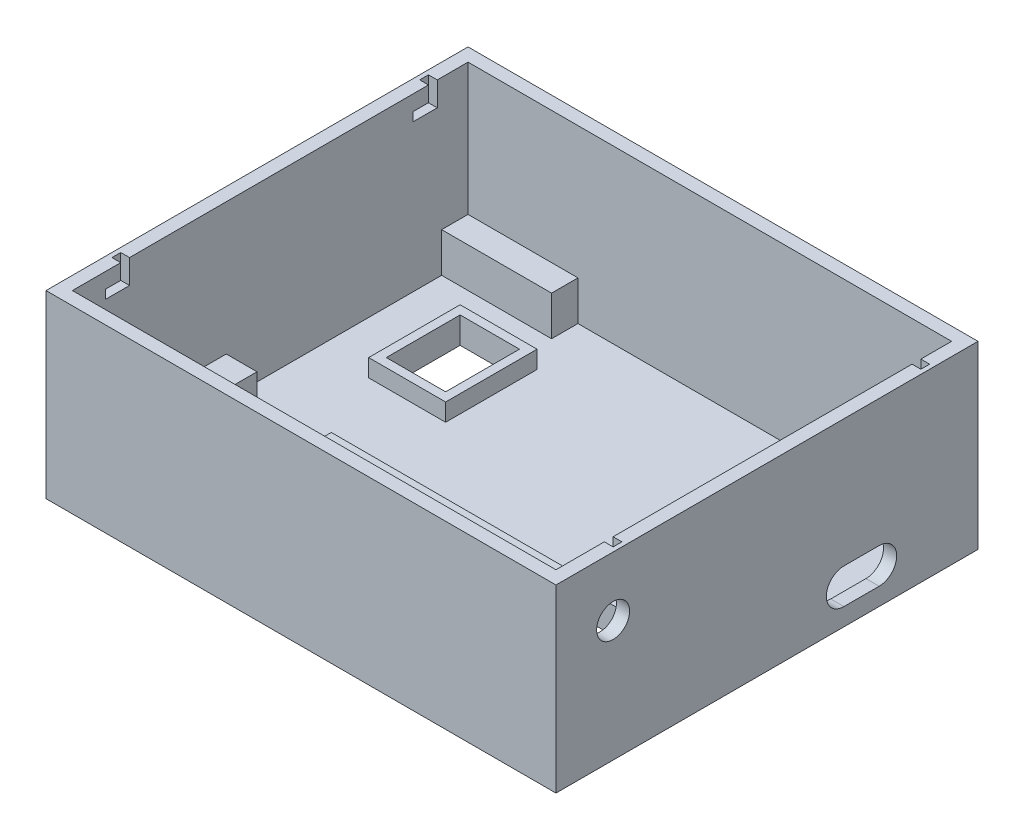
from build123d import *

# Parameters (mm, degrees)
SKETCH1_W           = 116
SKETCH1_H           = 96
BOSS_EXTRUDE1_DEPTH = 6
SKETCH2_W           = 116
SKETCH2_H           = 96
SKETCH2_W_2         = 110
SKETCH2_H_2         = 90
BOSS_EXTRUDE2_DEPTH = 35
SKETCH3_W           = 71.6
SKETCH3_H           = 24.5
SKETCH3_W_2         = 13.5
SKETCH3_H_2         = 16.8
CUT_EXTRUDE1_DEPTH  = 35
SKETCH4_W           = 5
SKETCH4_H           = 18
CUT_EXTRUDE2_DEPTH  = 4
SKETCH6_R           = 3.75
CUT_EXTRUDE3_DEPTH  = 3
SKETCH7_W           = 110
SKETCH7_H           = 90
SKETCH7_W_2         = 80.6
SKETCH7_H_2         = 28.5
SKETCH7_W_3         = 17.5
SKETCH7_H_3         = 20.8
CUT_EXTRUDE4_DEPTH  = 4
SKETCH8_W           = 7
SKETCH8_H           = 35
SKETCH8_W_2         = 15
SKETCH8_H_2         = 6
SKETCH8_W_3         = 25
BOSS_EXTRUDE3_DEPTH = 9
CUT_EXTRUDE6_START  = -1
CUT_EXTRUDE6_DEPTH  = 114


with BuildPart() as part:
    # Sketch1 → Boss-Extrude1 (new body)
    with BuildSketch(Plane(origin=(0, 0, 0), x_dir=(1, 0, 0), z_dir=(0, 1, 0))):
        Rectangle(SKETCH1_W, SKETCH1_H)
    extrude(amount=BOSS_EXTRUDE1_DEPTH)

    # Sketch2 → Boss-Extrude2 (add)
    with BuildSketch(Plane(origin=(0, 6, 0), x_dir=(1, 0, 0), z_dir=(0, 1, 0))):
        Rectangle(SKETCH2_W, SKETCH2_H)
        Rectangle(SKETCH2_W_2, SKETCH2_H_2, mode=Mode.SUBTRACT)
    extrude(amount=BOSS_EXTRUDE2_DEPTH)

    # Sketch3 → Cut-Extrude1 (cut)
    with BuildSketch(Plane(origin=(0, 6, 0), x_dir=(1, 0, 0), z_dir=(0, 1, 0))):
        with Locations((10.2, -22.75)):
            Rectangle(SKETCH3_W, SKETCH3_H)
        with Locations((-34.35, 20.9)):
            Rectangle(SKETCH3_W_2, SKETCH3_H_2)
    extrude(amount=-CUT_EXTRUDE1_DEPTH, mode=Mode.SUBTRACT)

    # Sketch4 → Cut-Extrude2 (cut)
    with BuildSketch(Plane(origin=(0, 6, 0), x_dir=(1, 0, 0), z_dir=(0, 1, 0))):
        with Locations((-28.1, -22.75)):
            Rectangle(SKETCH4_W, SKETCH4_H)
    extrude(amount=-CUT_EXTRUDE2_DEPTH, mode=Mode.SUBTRACT)

    # Sketch6 → Cut-Extrude3 (cut)
    with BuildSketch(Plane(origin=(58, 0, 0), x_dir=(0, 0, -1), z_dir=(1, 0, 0))):
        with Locations((-35, 27.500245912)):
            Circle(SKETCH6_R)
        with BuildLine():
            Line((17.5, 12), (25.5, 12))
            ThreePointArc((25.5, 12), (29.5, 8), (25.5, 4))
            Line((25.5, 4), (17.5, 4))
            ThreePointArc((17.5, 4), (13.5, 8), (17.5, 12))
        make_face()
    extrude(amount=-CUT_EXTRUDE3_DEPTH, mode=Mode.SUBTRACT)

    # Sketch7 → Cut-Extrude4 (cut)
    with BuildSketch(Plane(origin=(0, 6, 0), x_dir=(1, 0, 0), z_dir=(0, 1, 0))):
        Rectangle(SKETCH7_W, SKETCH7_H)
        with Locations((7.7, -22.75)):
            Rectangle(SKETCH7_W_2, SKETCH7_H_2, mode=Mode.SUBTRACT)
        with Locations((-34.35, 20.9)):
            Rectangle(SKETCH7_W_3, SKETCH7_H_3, mode=Mode.SUBTRACT)
    extrude(amount=-CUT_EXTRUDE4_DEPTH, mode=Mode.SUBTRACT)

    # Sketch8 → Boss-Extrude3 (add)
    with BuildSketch(Plane(origin=(0, 2, 0), x_dir=(1, 0, 0), z_dir=(0, 1, 0))):
        with Locations((-51.5, -27.5)):
            Rectangle(SKETCH8_W, SKETCH8_H)
        with Locations((47.5, 42)):
            Rectangle(SKETCH8_W_2, SKETCH8_H_2)
        with Locations((-42.5, 42)):
            Rectangle(SKETCH8_W_3, SKETCH8_H_2)
    extrude(amount=BOSS_EXTRUDE3_DEPTH)

    # Sketch10 → Cut-Extrude6 (cut)
    with BuildSketch(Plane(origin=(58, 0, 0), x_dir=(0, 0, -1), z_dir=(1, 0, 0)).offset(CUT_EXTRUDE6_START)):
        Polygon((-32, 41), (-32, 35.5), (-37.5, 35.5), (-37.5, 37.5), (-34, 37.5), (-34, 41), align=None)
        Polygon((36, 41), (38, 41), (38, 35.5), (32.5, 35.5), (32.5, 37.5), (36, 37.5), align=None)
    extrude(amount=-CUT_EXTRUDE6_DEPTH, mode=Mode.SUBTRACT)


solid = part.part
